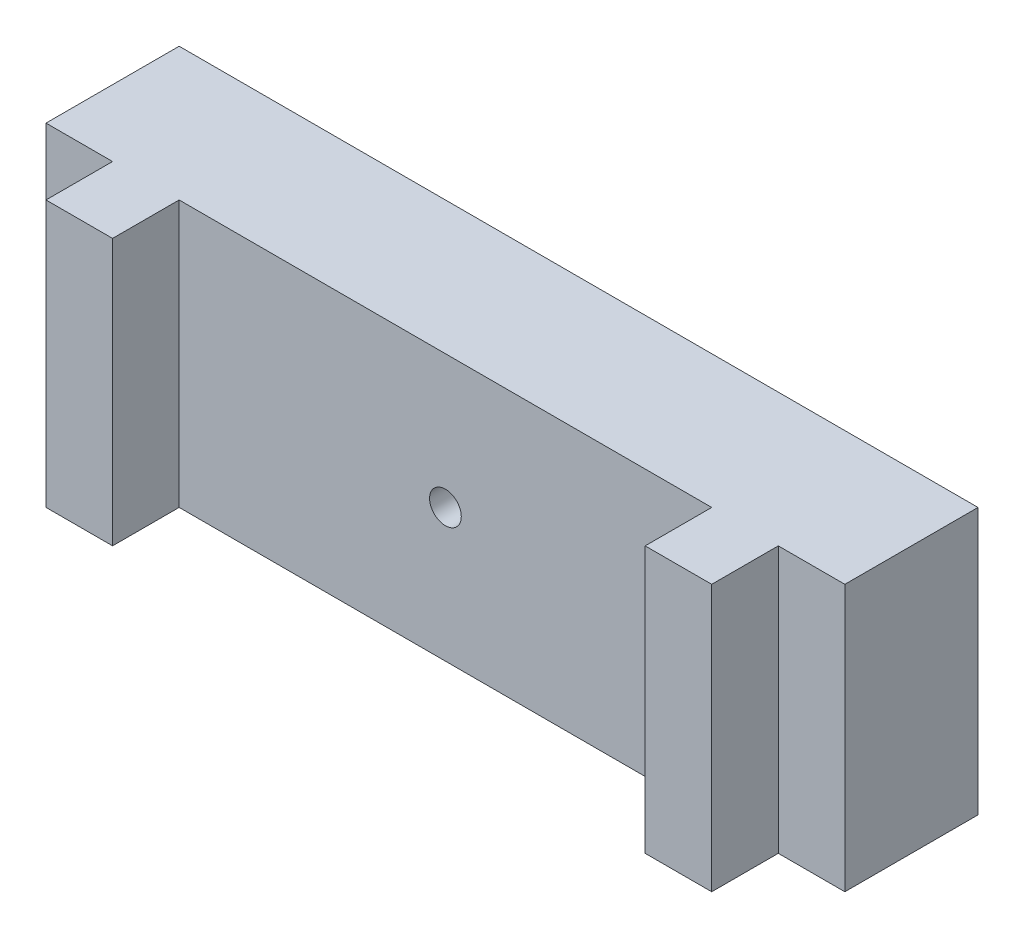
from build123d import *

# Parameters (mm, degrees)
BOSS_EXTRUDE1_DEPTH      = 6.35
BOSS_EXTRUDE1_DEPTH_BACK = 6.35
SKETCH1_W                = 76.2
SKETCH1_H                = 25.4
SKETCH4_W                = 6.35
SKETCH4_H                = 25.4
BOSS_EXTRUDE3_DEPTH      = 6.35
SKETCH6_R                = 1.5113
CUT_EXTRUDE1_DEPTH       = 43.121134838


with BuildPart() as part:
    # Sketch1 → Boss-Extrude1 (new, two sides: drawn at the far end of the back side and taken through both)
    with BuildSketch(Plane.XY.offset(-BOSS_EXTRUDE1_DEPTH_BACK)):
        Rectangle(SKETCH1_W, SKETCH1_H)
    extrude(amount=BOSS_EXTRUDE1_DEPTH + BOSS_EXTRUDE1_DEPTH_BACK)

    # Sketch4 → Boss-Extrude3 (add)
    with BuildSketch(Plane.XY.offset(6.35)):
        with Locations((-28.575, 0)):
            Rectangle(SKETCH4_W, SKETCH4_H)
        with Locations((28.575, 0)):
            Rectangle(SKETCH4_W, SKETCH4_H)
    extrude(amount=BOSS_EXTRUDE3_DEPTH)

    # Sketch6 → Cut-Extrude1 (cut, through all)
    with BuildSketch(Plane.XY.offset(6.35)):
        Circle(SKETCH6_R)
    extrude(amount=-CUT_EXTRUDE1_DEPTH, mode=Mode.SUBTRACT)


solid = part.part
